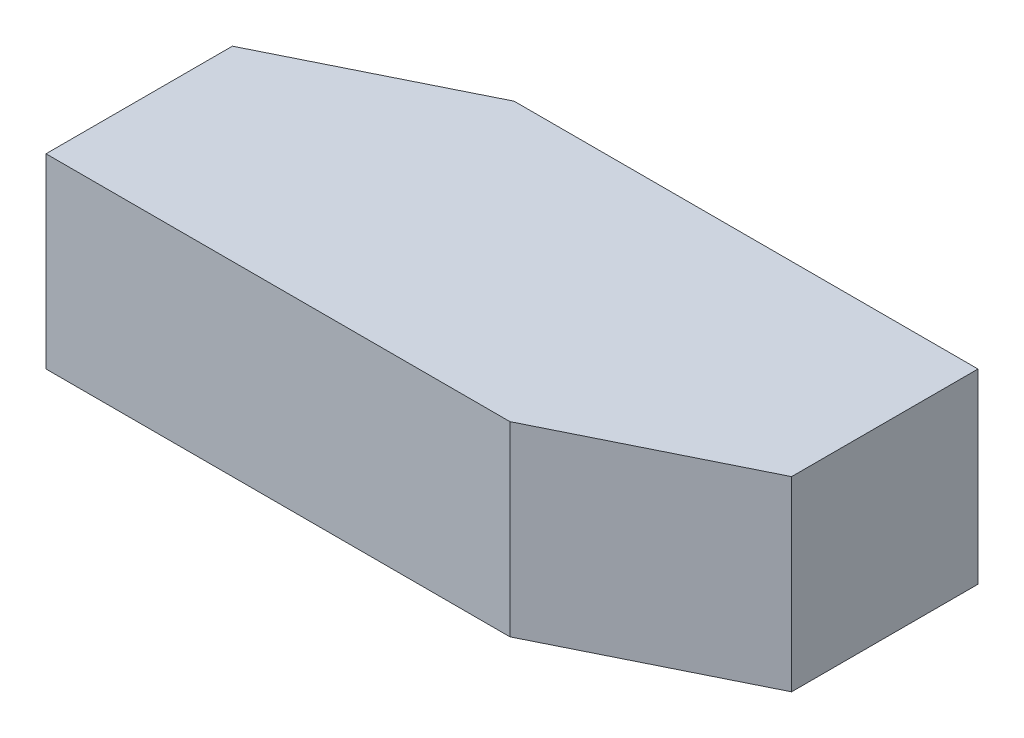
from build123d import *

# Parameters (mm, degrees)
BOSS_EXTRUDE1_DEPTH = 4


with BuildPart() as part:
    # Sketch1 → Boss-Extrude1 (new body)
    with BuildSketch(Plane(origin=(0, 0, 0), x_dir=(1, 0, 0), z_dir=(0, 1, 0))):
        Polygon((-14.671203832, -23.651639708), (-4.715841455, -23.651639708), (-0.671203832, -21.651639708), (-0.671203832, -17.651639708), (-10.62656621, -17.651639708), (-14.671203832, -19.651639708), align=None)
    extrude(amount=BOSS_EXTRUDE1_DEPTH)


solid = part.part
